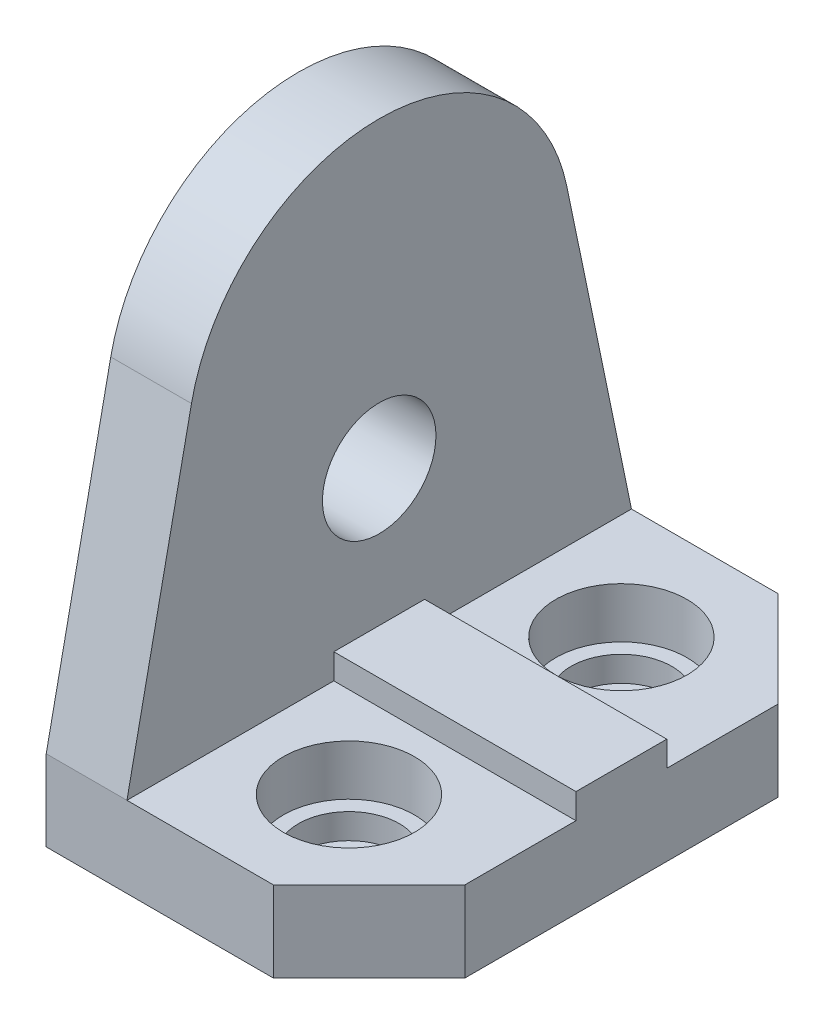
from build123d import *

# Parameters (mm, degrees)
BOSS_EXTRUDE1_DEPTH   = 32
BOSS_EXTRUDE1_2_DEPTH = 32
SKETCH1_3_W           = 128
SKETCH1_3_H           = 36
BOSS_EXTRUDE2_DEPTH   = 42
SKETCH2_R             = 22.5
BOSS_EXTRUDE3_DEPTH   = 32
SKETCH4_R             = 26
CUT_EXTRUDE1_DEPTH    = 20
SKETCH4_3_R           = 20
CUT_EXTRUDE2_DEPTH    = 30


with BuildPart() as part:
    # Sketch1 → Boss-Extrude1 (new body)
    with BuildSketch(Plane(origin=(0, 0, 0), x_dir=(1, 0, 0), z_dir=(0, 1, 0))):
        Polygon((0, -18), (0, -100), (90, -100), (128, -62), (128, -18), align=None)
    extrude(amount=BOSS_EXTRUDE1_DEPTH)



with BuildPart() as body_2:
    # Sketch1 → Boss-Extrude1 2 (new body)
    with BuildSketch(Plane(origin=(0, 0, 0), x_dir=(1, 0, 0), z_dir=(0, 1, 0))):
        Polygon((0, 100), (0, 18), (128, 18), (128, 62), (90, 100), align=None)
    extrude(amount=BOSS_EXTRUDE1_2_DEPTH)


with BuildPart() as part_1:
    add(part.part)

    add(body_2.part)  # Boss-Extrude2 merges body 2
    # Sketch1_3 → Boss-Extrude2 (add)
    with BuildSketch(Plane(origin=(0, 0, 0), x_dir=(1, 0, 0), z_dir=(0, 1, 0))):
        with Locations((64, 0)):
            Rectangle(SKETCH1_3_W, SKETCH1_3_H)
    extrude(amount=BOSS_EXTRUDE2_DEPTH)

    # Sketch2 → Boss-Extrude3 (add)
    with BuildSketch(Plane(origin=(0, 0, 0), x_dir=(0, 0, -1), z_dir=(1, 0, 0))):
        with BuildLine():
            Line((-100, 32), (-74.418333794, 155.424383143))
            ThreePointArc((-74.418333794, 155.424383143), (0, 216), (74.418333794, 155.424383143))
            Line((74.418333794, 155.424383143), (100, 32))
            Line((100, 32), (-100, 32))
        make_face()
        with Locations((0, 96)):
            Circle(SKETCH2_R, mode=Mode.SUBTRACT)
    extrude(amount=BOSS_EXTRUDE3_DEPTH)

    # Sketch4 → Cut-Extrude1 (cut)
    with BuildSketch(Plane(origin=(0, 32, 0), x_dir=(1, 0, 0), z_dir=(0, 1, 0))):
        with Locations((74, -54)):
            Circle(SKETCH4_R)
        with Locations((74, 54)):
            Circle(SKETCH4_R)
    extrude(amount=-CUT_EXTRUDE1_DEPTH, mode=Mode.SUBTRACT)

    # Sketch4_3 → Cut-Extrude2 (cut)
    with BuildSketch(Plane(origin=(0, 32, 0), x_dir=(1, 0, 0), z_dir=(0, 1, 0))):
        with Locations((74, -54)):
            Circle(SKETCH4_3_R)
        with Locations((74, 54)):
            Circle(SKETCH4_3_R)
    extrude(amount=-CUT_EXTRUDE2_DEPTH, mode=Mode.SUBTRACT)


solid = part_1.part
